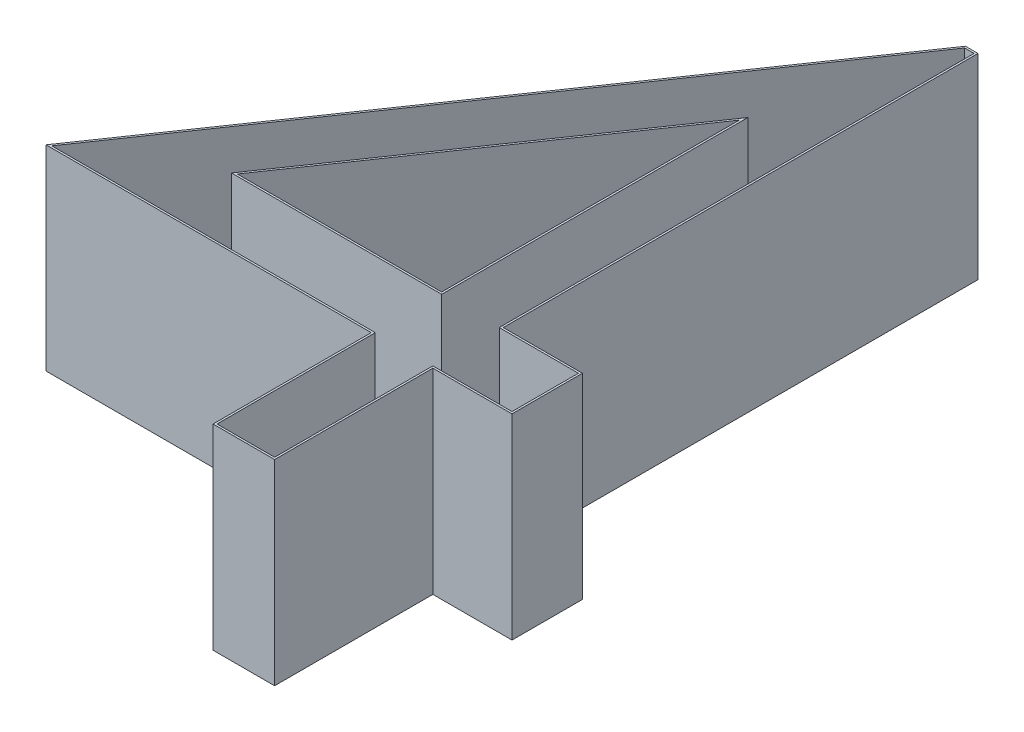
from build123d import *

# Parameters (mm, degrees)
BOSS_EXTRUDE1_DEPTH = 1
CUT_EXTRUDE2_DEPTH  = 1


with BuildPart() as part:
    # Sketch1 → Boss-Extrude1 (new body)
    with BuildSketch(Plane(origin=(0, 0, 0), x_dir=(1, 0, 0), z_dir=(0, 1, 0))):
        Polygon((2.045172276, 3.58974359), (2.108974359, 3.58974359), (2.108974359, 1.166666667), (2.512820513, 1.166666667), (2.512820513, 0.807692308), (2.108974359, 0.807692308), (2.108974359, 0), (1.794871795, 0), (1.794871795, 0.807692308), (0.134615385, 0.807692308), align=None)
        Polygon((1.794871795, 1.166666667), (1.794871795, 2.686698718), (0.751602564, 1.166666667), align=None, mode=Mode.SUBTRACT)
    extrude(amount=BOSS_EXTRUDE1_DEPTH)

    # Sketch2 → Cut-Extrude2 (cut)
    with BuildSketch(Plane(origin=(0, 1, 0), x_dir=(1, 0, 0), z_dir=(0, 1, 0))):
        Polygon((2.050435859, 3.57974359), (0.153613847, 0.817692308), (1.804871795, 0.817692308), (1.804871795, 0.01), (2.098974359, 0.01), (2.098974359, 0.817692308), (2.502820513, 0.817692308), (2.502820513, 1.156666667), (2.098974359, 1.156666667), (2.098974359, 3.57974359), align=None)
        Polygon((0.73261032, 1.156666667), (1.804871795, 1.156666667), (1.804871795, 2.718940106), align=None, mode=Mode.SUBTRACT)
    extrude(amount=-CUT_EXTRUDE2_DEPTH, mode=Mode.SUBTRACT)


solid = part.part
